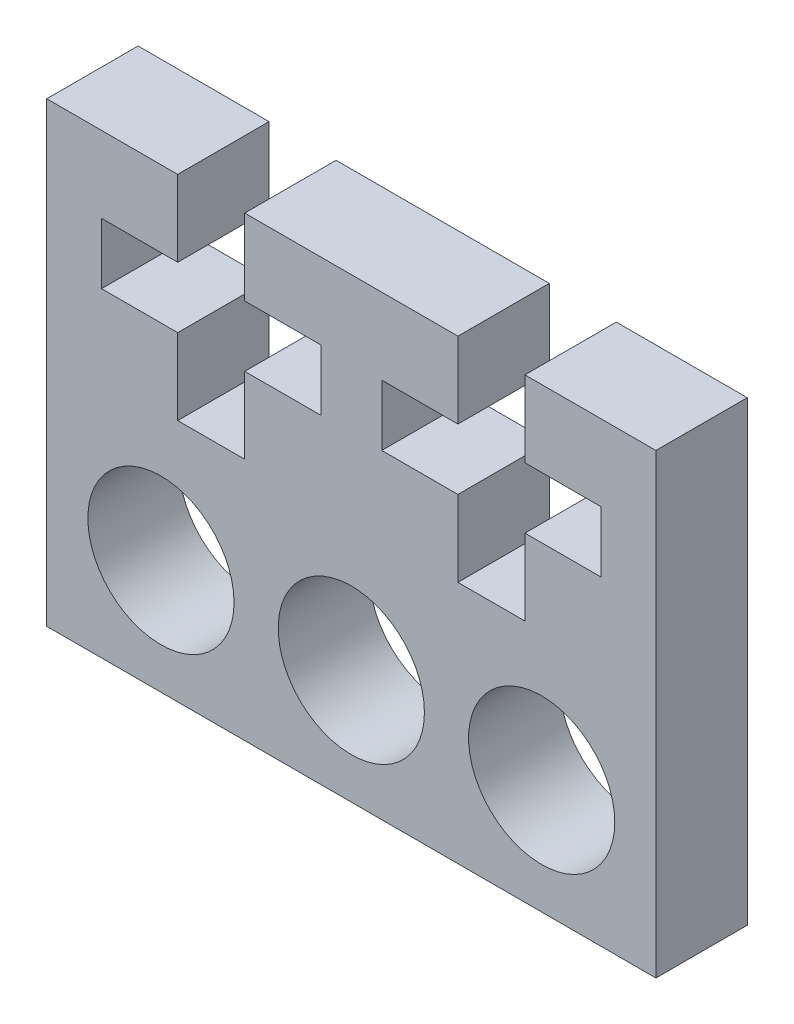
from build123d import *

# Parameters (mm, degrees)
SKETCH1_R           = 2.4
BOSS_EXTRUDE1_DEPTH = 3


with BuildPart() as part:
    # Sketch1 → Boss-Extrude1 (new body)
    with BuildSketch(Plane.XY):
        Polygon((-10, -7.5), (10, -7.5), (10, 7.5), (5.7, 7.5), (5.7, 5), (8.2, 5), (8.2, 3), (5.7, 3), (5.7, 0.5), (3.5, 0.5), (3.5, 3), (1, 3), (1, 5), (3.5, 5), (3.5, 7.5), (-3.5, 7.5), (-3.5, 5), (-1, 5), (-1, 3), (-3.5, 3), (-3.5, 0.5), (-5.7, 0.5), (-5.7, 3), (-8.2, 3), (-8.2, 5), (-5.7, 5), (-5.7, 7.5), (-10, 7.5), align=None)
        with Locations((0, -3.75)):
            Circle(SKETCH1_R, mode=Mode.SUBTRACT)
        with Locations((-6.25, -3.75)):
            Circle(SKETCH1_R, mode=Mode.SUBTRACT)
        with Locations((6.25, -3.75)):
            Circle(SKETCH1_R, mode=Mode.SUBTRACT)
    extrude(amount=BOSS_EXTRUDE1_DEPTH)


solid = part.part
